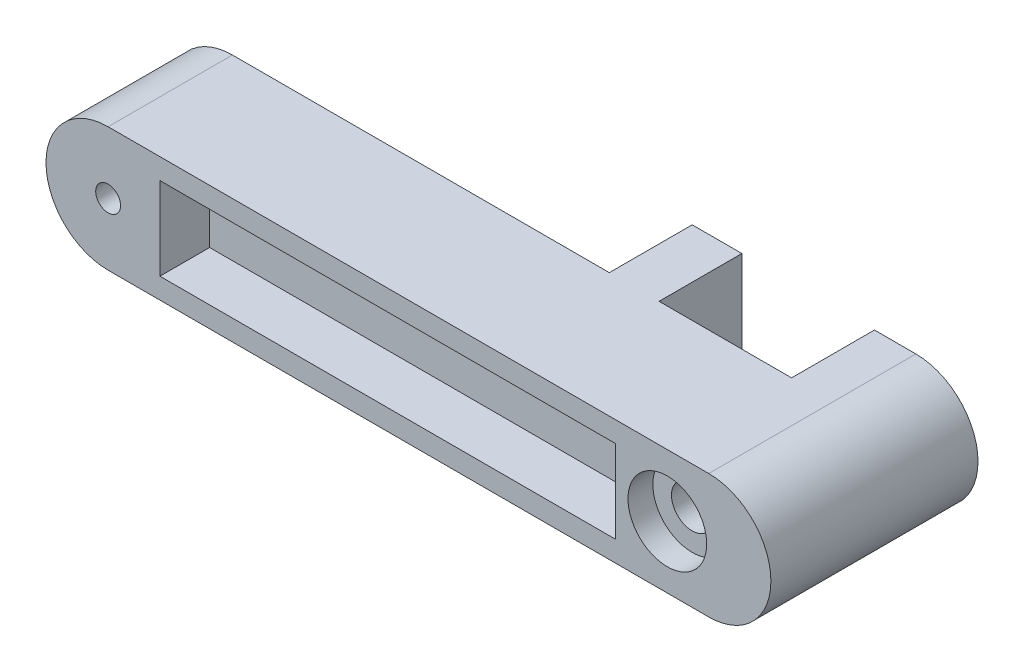
from build123d import *

# Parameters (mm, degrees)
BOSS_EXTRUDE1_DEPTH   = 30
SKETCH2_R             = 3
CUT_EXTRUDE1_DEPTH    = 30
SKETCH3_R             = 9.5
CUT_EXTRUDE2_DEPTH    = 6
SKETCH4_R             = 9.5
CUT_EXTRUDE3_DEPTH    = 6
CUT_EXTRUDE4_REACH    = 26
SKETCH5_R             = 5
SKETCH6_W             = 110
SKETCH6_H             = 20
CUT_EXTRUDE5_DEPTH    = 12
SKETCH7_W             = 110
SKETCH7_H             = 20
CUT_EXTRUDE6_DEPTH    = 12
SKETCH8_W             = 12
SKETCH8_H             = 30
BOSS_EXTRUDE2_DEPTH   = 32
CUT_EXTRUDE7_DEPTH    = 35
BOSS_EXTRUDE3_DEPTH   = 50
SKETCH11_R            = 1.5
CUT_EXTRUDE8_DEPTH    = 10
SKETCH13_R            = 1.5
CUT_EXTRUDE9_DEPTH    = 10
SKETCH12_R            = 1.5
CUT_EXTRUDE10_DEPTH   = 10
BODY_MOVE_COPY1_ANGLE = 90


with BuildPart() as part:
    # Sketch1 → Boss-Extrude1 (new body)
    with BuildSketch(Plane(origin=(0, 0, 0), x_dir=(0, 0, -1), z_dir=(1, 0, 0))):
        with BuildLine():
            Line((0, 30), (135, 30))
            ThreePointArc((135, 30), (150, 15), (135, 0))
            Line((135, 0), (0, 0))
            ThreePointArc((0, 0), (-15, 15), (0, 30))
        make_face()
    extrude(amount=BOSS_EXTRUDE1_DEPTH)

    # Sketch2 → Cut-Extrude1 (cut)
    with BuildSketch(Plane(origin=(30, 0, 0), x_dir=(0, 0, -1), z_dir=(1, 0, 0))):
        with Locations((0, 15)):
            Circle(SKETCH2_R)
    extrude(amount=-CUT_EXTRUDE1_DEPTH, mode=Mode.SUBTRACT)

    # Sketch3 → Cut-Extrude2 (cut)
    with BuildSketch(Plane(origin=(30, 0, 0), x_dir=(0, 0, -1), z_dir=(1, 0, 0))):
        with Locations((135, 15)):
            Circle(SKETCH3_R)
    extrude(amount=-CUT_EXTRUDE2_DEPTH, mode=Mode.SUBTRACT)

    # Sketch4 → Cut-Extrude3 (cut)
    with BuildSketch(Plane.ZY):
        with Locations((-135, 15)):
            Circle(SKETCH4_R)
    extrude(amount=-CUT_EXTRUDE3_DEPTH, mode=Mode.SUBTRACT)

    # Sketch5 → Cut-Extrude4 (cut, up to next)
    with BuildSketch(Plane.ZY.offset(-6), mode=Mode.PRIVATE) as cut_extrude4_sk1:
        with Locations((-135, 15)):
            Circle(SKETCH5_R)
    cut_extrude4_tool1 = extrude(cut_extrude4_sk1.sketch, amount=-CUT_EXTRUDE4_REACH, mode=Mode.PRIVATE) & part.part
    add(cut_extrude4_tool1.solids().sort_by_distance((6, 15, -135))[0], mode=Mode.SUBTRACT)

    # Sketch6 → Cut-Extrude5 (cut)
    with BuildSketch(Plane(origin=(30, 0, 0), x_dir=(0, 0, -1), z_dir=(1, 0, 0))):
        with Locations((67.5, 15)):
            Rectangle(SKETCH6_W, SKETCH6_H)
    extrude(amount=-CUT_EXTRUDE5_DEPTH, mode=Mode.SUBTRACT)

    # Sketch7 → Cut-Extrude6 (cut)
    with BuildSketch(Plane.ZY):
        with Locations((-67.5, 15)):
            Rectangle(SKETCH7_W, SKETCH7_H)
    extrude(amount=-CUT_EXTRUDE6_DEPTH, mode=Mode.SUBTRACT)

    # Sketch8 → Boss-Extrude2 (add)
    with BuildSketch(Plane.ZY.offset(-12)):
        with Locations((-97, 15)):
            Rectangle(SKETCH8_W, SKETCH8_H)
        with Locations((-151, 15)):
            Rectangle(SKETCH8_W, SKETCH8_H)
    extrude(amount=BOSS_EXTRUDE2_DEPTH)

    # Sketch9 → Cut-Extrude7 (cut)
    with BuildSketch(Plane(origin=(12, 0, 0), x_dir=(0, 0, -1), z_dir=(1, 0, 0))):
        with BuildLine():
            Line((145, 30), (145, 26.180339887))
            ThreePointArc((145, 26.180339887), (150, 15), (145, 3.819660113))
            Line((145, 3.819660113), (145, 0))
            Line((145, 0), (157, 0))
            Line((157, 0), (157, 30))
            Line((157, 30), (145, 30))
        make_face()
    extrude(amount=-CUT_EXTRUDE7_DEPTH, mode=Mode.SUBTRACT)

    # Sketch10 → Boss-Extrude3 (add)
    with BuildSketch(Plane(origin=(30, 0, 0), x_dir=(0, 0, -1), z_dir=(1, 0, 0))):
        with BuildLine():
            Line((135, 30), (145, 30))
            ThreePointArc((145, 30), (160, 15), (145, 0))
            Line((145, 0), (135, 0))
            ThreePointArc((135, 0), (150, 15), (135, 30))
        make_face()
    extrude(amount=-BOSS_EXTRUDE3_DEPTH)

    # Sketch11 → Cut-Extrude8 (cut)
    with BuildSketch(Plane.ZY.offset(20)):
        with Locations((-149.85, 10.350189987)):
            Circle(SKETCH11_R)
    extrude(amount=-CUT_EXTRUDE8_DEPTH, mode=Mode.SUBTRACT)

    # Sketch13 → Cut-Extrude9 (cut)
    with BuildSketch(Plane.ZY.offset(20)):
        with Locations((-149.85, 20.350189987)):
            Circle(SKETCH13_R)
        with Locations((-99.35, 20.350189987)):
            Circle(SKETCH13_R)
    extrude(amount=-CUT_EXTRUDE9_DEPTH, mode=Mode.SUBTRACT)

    # Sketch12 → Cut-Extrude10 (cut)
    with BuildSketch(Plane.ZY.offset(20)):
        with Locations((-99.35, 10.350189987)):
            Circle(SKETCH12_R)
    extrude(amount=-CUT_EXTRUDE10_DEPTH, mode=Mode.SUBTRACT)


with BuildPart() as part_1:
    # Body-Move/Copy1: moved
    add(part.part.rotate(Axis((5, 0, -72.5), (0, -1, 0)), BODY_MOVE_COPY1_ANGLE))


with BuildPart() as part_2:
    # Body-Move/Copy2: moved
    add(part_1.part.moved(Location((67.5, -15, 47.5))))


solid = part_2.part
